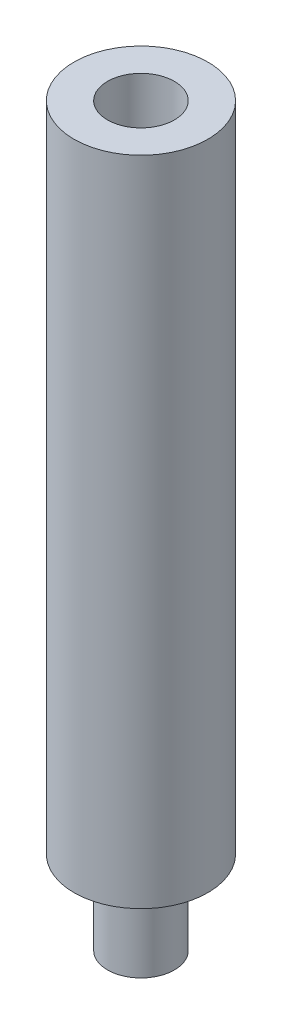
from build123d import *

# Parameters (mm, degrees)
ESQUISSE1_R             = 4
BOSS_EXTRU_1_DEPTH      = 39
ESQUISSE3_R             = 2
ENL_V_MAT_EXTRU_1_DEPTH = 10
ESQUISSE4_R             = 2
BOSS_EXTRU_2_DEPTH      = 5


with BuildPart() as part:
    # Esquisse1 → Boss.-Extru.1 (new body)
    with BuildSketch(Plane(origin=(0, 0, 0), x_dir=(1, 0, 0), z_dir=(0, 1, 0))):
        Circle(ESQUISSE1_R)
    extrude(amount=-BOSS_EXTRU_1_DEPTH)

    # Esquisse3 → Enlèv. mat.-Extru.1 (cut)
    with BuildSketch(Plane(origin=(0, 0, 0), x_dir=(1, 0, 0), z_dir=(0, 1, 0))):
        Circle(ESQUISSE3_R)
    extrude(amount=-ENL_V_MAT_EXTRU_1_DEPTH, mode=Mode.SUBTRACT)

    # Esquisse4 → Boss.-Extru.2 (add)
    with BuildSketch(Plane.XZ.offset(39)):
        Circle(ESQUISSE4_R)
    extrude(amount=BOSS_EXTRU_2_DEPTH)


solid = part.part
